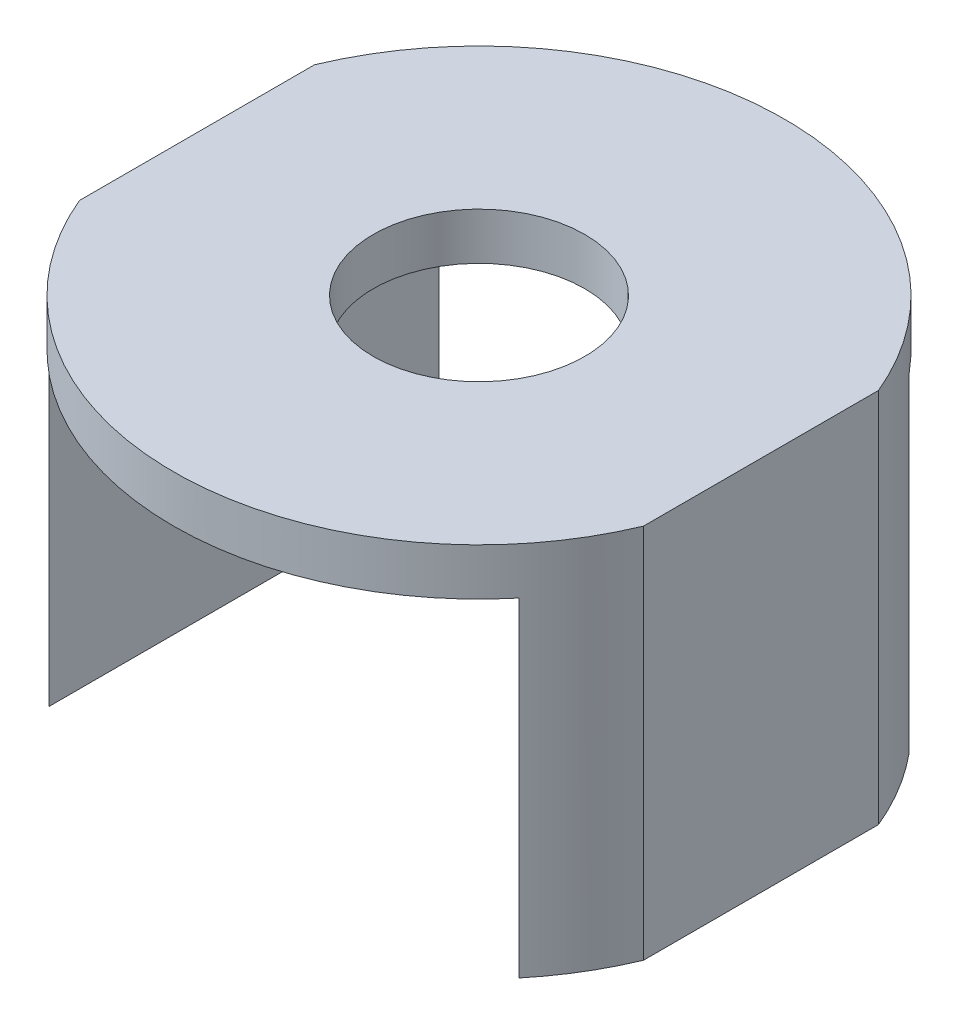
from build123d import *

# Parameters (mm, degrees)
SKETCH1_W           = 76.2
SKETCH1_H           = 50.8
SKETCH1_W_2         = 63.5
SKETCH1_H_2         = 38.1
BOSS_EXTRUDE1_DEPTH = 114.3
SKETCH2_R           = 14.2875
CUT_EXTRUDE2_DEPTH  = 114.3
SKETCH3_W           = 63.5
SKETCH3_H           = 101.6
CUT_EXTRUDE3_DEPTH  = 7.62


with BuildPart() as part:
    # Sketch1 → Boss-Extrude1 (new body)
    with BuildSketch(Plane.XY):
        Rectangle(SKETCH1_W, SKETCH1_H)
        Rectangle(SKETCH1_W_2, SKETCH1_H_2, mode=Mode.SUBTRACT)
    extrude(amount=BOSS_EXTRUDE1_DEPTH)

    # Sketch2 → Cut-Extrude2 (cut)
    with BuildSketch(Plane(origin=(0, 25.4, 0), x_dir=(1, 0, 0), z_dir=(0, 1, 0))):
        with BuildLine():
            Line((38.1, -114.3), (38.1, -73.025))
            ThreePointArc((38.1, -73.025), (0, -98.425), (-38.1, -73.025))
            Line((-38.1, -73.025), (-38.1, -114.3))
            Line((-38.1, -114.3), (38.1, -114.3))
        make_face()
        with Locations((0, -57.15)):
            Circle(SKETCH2_R)
        with BuildLine():
            ThreePointArc((-38.1, -41.275), (0, -15.875), (38.1, -41.275))
            Line((38.1, -41.275), (38.1, 0))
            Line((38.1, 0), (-38.1, 0))
            Line((-38.1, 0), (-38.1, -41.275))
        make_face()
    extrude(amount=-CUT_EXTRUDE2_DEPTH, mode=Mode.SUBTRACT)

    # Sketch3 → Cut-Extrude3 (cut)
    with BuildSketch(Plane.XZ.offset(25.4)):
        with Locations((0, 57.15)):
            Rectangle(SKETCH3_W, SKETCH3_H)
    extrude(amount=-CUT_EXTRUDE3_DEPTH, mode=Mode.SUBTRACT)


solid = part.part
